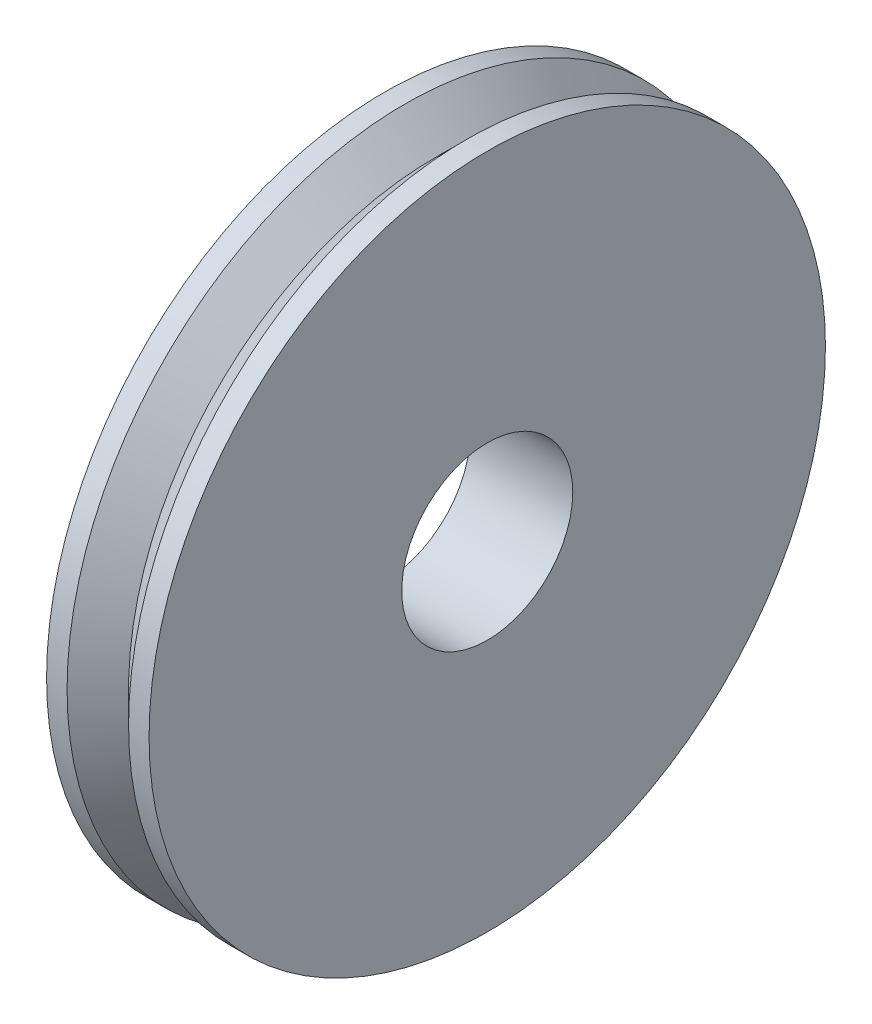
from build123d import *

# Parameters (mm, degrees)
SKETCH1_R           = 19.05
BOSS_EXTRUDE1_DEPTH = 1.905
SKETCH6_R           = 5.3
CUT_EXTRUDE2_DEPTH  = 7.35


with BuildPart() as part:
    # Sketch1 → Boss-Extrude1 (new body, symmetric)
    with BuildSketch(Plane(origin=(32.015745885, 0, 0), x_dir=(0, 0, -1), z_dir=(1, 0, 0))):
        with Locations((136.328078847, 49.836172535)):
            Circle(SKETCH1_R)
    extrude(amount=BOSS_EXTRUDE1_DEPTH, both=True)

    # Sketch5 → Revolve1 (revolve)
    with BuildSketch(Plane(origin=(0, 0, -136.328078847), x_dir=(-1, 0, 0), z_dir=(0, 0, -1))):
        Polygon((-32.015745885, 68.886172535), (-33.920745885, 70.791172535), (-35.190745885, 70.791172535), (-35.190745885, 49.836172535), (-33.920745885, 49.836172535), (-33.920745885, 68.886172535), align=None)
    revolve1 = revolve(axis=Axis((33.920745885, 49.836172535, -136.328078847), (-1, 0, 0)))

    # Mirror2: Revolve1 across plane
    add(revolve1.mirror(Plane(origin=(32.015745885, 0, 0), x_dir=(0, 0, 1), z_dir=(1, 0, 0))))

    # Sketch6 → Cut-Extrude2 (cut, through all)
    with BuildSketch(Plane(origin=(35.190745885, 0, 0), x_dir=(0, 0, -1), z_dir=(1, 0, 0))):
        with Locations((136.328078847, 49.836172535)):
            Circle(SKETCH6_R)
    extrude(amount=-CUT_EXTRUDE2_DEPTH, mode=Mode.SUBTRACT)


solid = part.part
